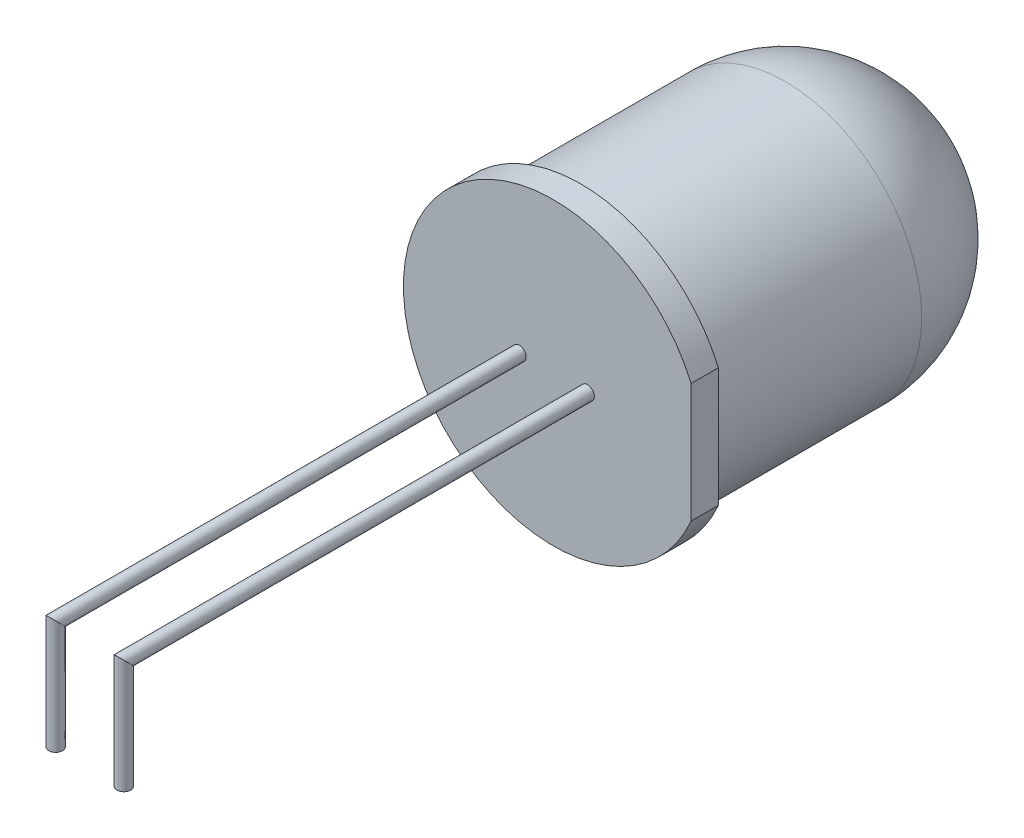
from build123d import *

# Parameters (mm, degrees)
ESQUISSE1_R          = 5
BASE_EXTRUSION_DEPTH = 13.5
BOSS_EXTRU_1_DEPTH   = 1
CONG_1_R             = 5
ESQUISSE3_R          = 0.25


with BuildPart() as part:
    # Esquisse1 → Base-Extrusion (new body)
    with BuildSketch(Plane.XY):
        Circle(ESQUISSE1_R)
    extrude(amount=BASE_EXTRUSION_DEPTH)

    # Esquisse2 → Boss.-Extru.1 (add)
    with BuildSketch(Plane.XY.offset(13.5)):
        with BuildLine():
            Line((5.047640875, 2.184335504), (5.047640875, -2.184335504))
            ThreePointArc((5.047640875, -2.184335504), (-5.5, 0), (5.047640875, 2.184335504))
        make_face()
    extrude(amount=-BOSS_EXTRU_1_DEPTH)

    # Congé1
    cong_1_edges = [part.edges().sort_by_distance(p)[0] for p in [
        (-5, 0, 0),
    ]]
    fillet(cong_1_edges, radius=CONG_1_R)

    # Balayage1: sweep along a path in Esquisse4
    with BuildLine(Plane(origin=(-1.25, 0, 0), x_dir=(0, 0, -1), z_dir=(1, 0, 0))) as balayage1_path:
        Line((-13.5, 0), (-30.5, 0))
        Line((-30.5, 0), (-30.5, -4))
    # Esquisse3 → Balayage1 (sweep)
    with BuildSketch(Plane.XY.offset(13.5)):
        with Locations((-1.25, 0)):
            Circle(ESQUISSE3_R)
    balayage1 = sweep(path=balayage1_path.line, transition=Transition.RIGHT)

    # Symétrie1: Balayage1 across plane
    add(balayage1.mirror(Plane(origin=(0, 0, 0), x_dir=(0, 0, 1), z_dir=(1, 0, 0))))


solid = part.part
